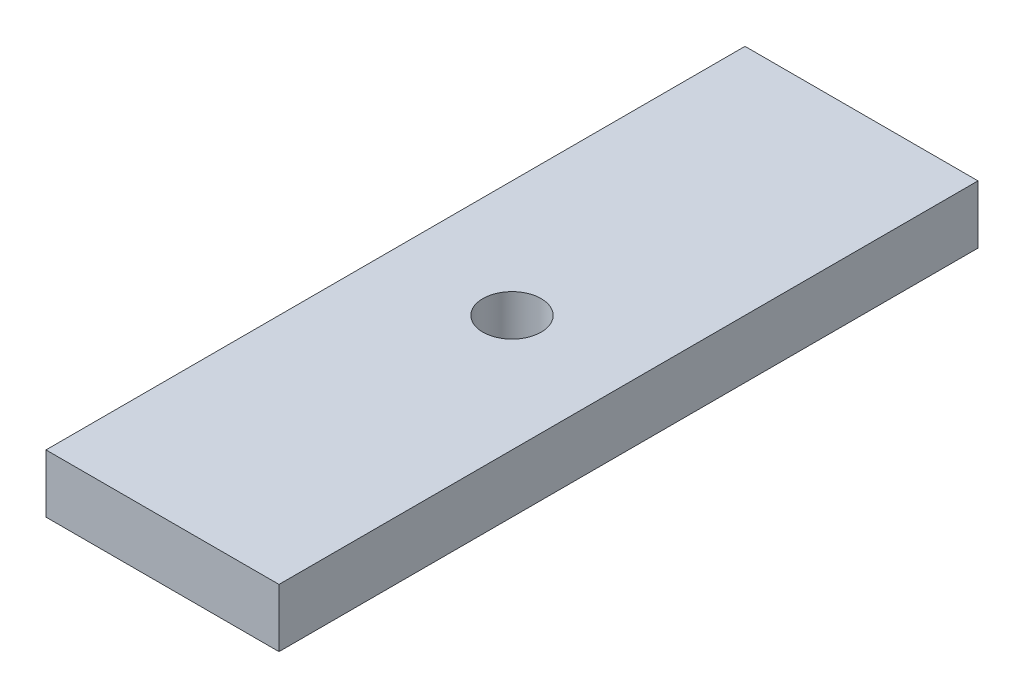
from build123d import *

# Parameters (mm, degrees)
BOSS_EXTRUDE1_DEPTH = 10


with BuildPart() as part:
    # Sketch1 → Boss-Extrude1 (new body)
    with BuildSketch(Plane(origin=(0, 0, 0), x_dir=(1, 0, 0), z_dir=(0, 1, 0))):
        with BuildLine():
            Line((0, 120), (0, 60))
            Line((0, 60), (15, 60))
            ThreePointArc((15, 60), (20, 65), (25, 60))
            Line((25, 60), (40, 60))
            Line((40, 60), (40, 120))
            Line((40, 120), (0, 120))
        make_face()
        with BuildLine():
            Line((0, 60), (0, 0))
            Line((0, 0), (40, 0))
            Line((40, 0), (40, 60))
            Line((40, 60), (25, 60))
            ThreePointArc((25, 60), (20, 55), (15, 60))
            Line((15, 60), (0, 60))
        make_face()
    extrude(amount=BOSS_EXTRUDE1_DEPTH)


solid = part.part
